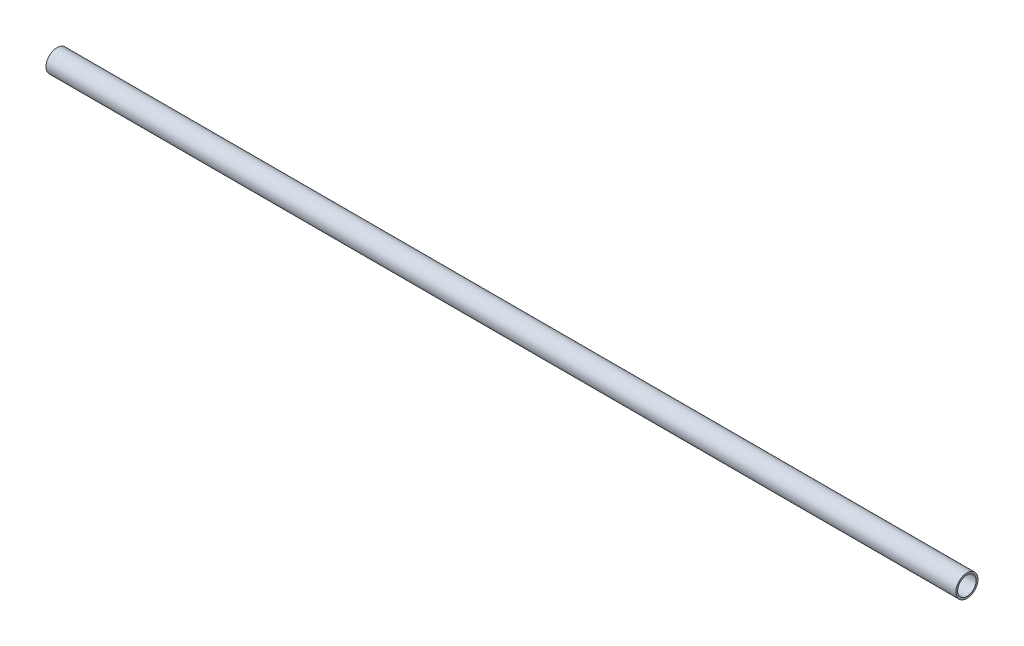
from build123d import *

# Parameters (mm, degrees)
SKETCH1_R           = 24.13
SKETCH1_R_2         = 20.193
BOSS_EXTRUDE1_DEPTH = 1981.2


with BuildPart() as part:
    # Sketch1 → Boss-Extrude1 (new body)
    with BuildSketch(Plane(origin=(0, 0, 0), x_dir=(0, 0, -1), z_dir=(1, 0, 0))):
        Circle(SKETCH1_R)
        Circle(SKETCH1_R_2, mode=Mode.SUBTRACT)
    extrude(amount=BOSS_EXTRUDE1_DEPTH)


solid = part.part
